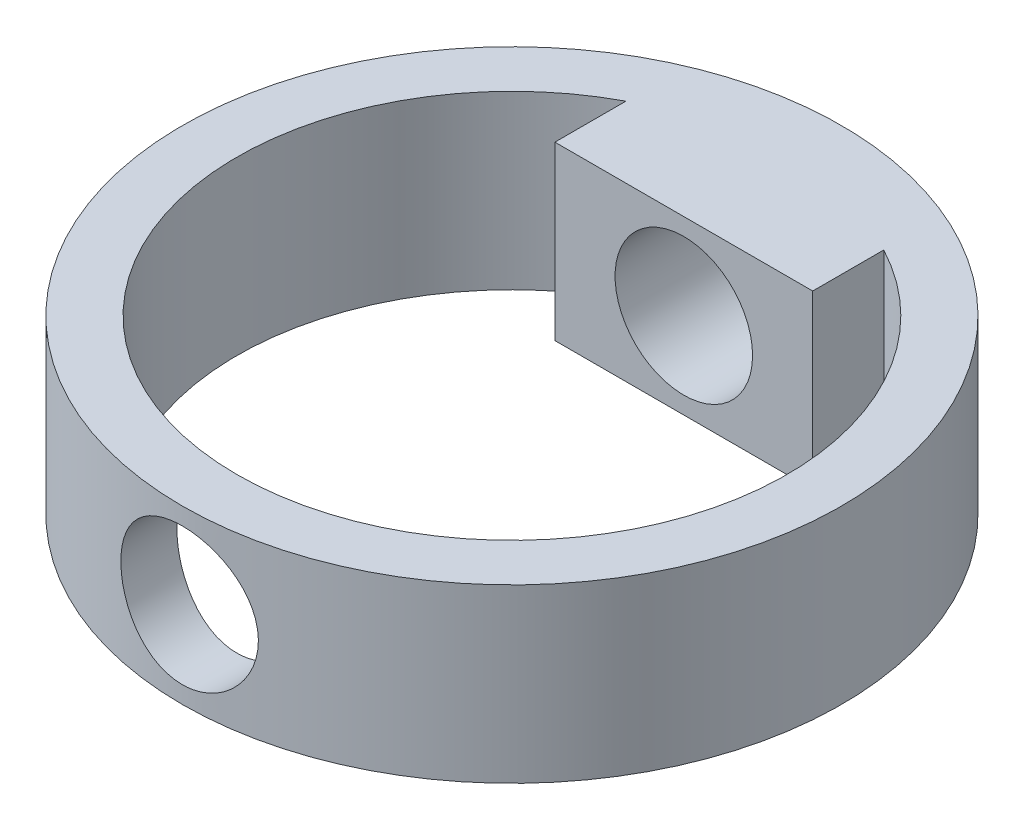
from build123d import *

# Parameters (mm, degrees)
SKETCH6_R               = 19.175
SKETCH6_R_2             = 16
BOSS_EXTRUDE4_DEPTH     = 5
BOSS_EXTRUDE6_REACH     = 37.268
SKETCH8_W               = 15
SKETCH8_H               = 10
CUT_EXTRUDE1_DEPTH      = 31.264603913
CUT_EXTRUDE1_DEPTH_BACK = 31.264603913
SKETCH7_2_R             = 4


with BuildPart() as part:
    # Sketch6 → Boss-Extrude4 (new, symmetric)
    with BuildSketch(Plane(origin=(0, 0, 0), x_dir=(1, 0, 0), z_dir=(0, 1, 0))):
        Circle(SKETCH6_R)
        Circle(SKETCH6_R_2, mode=Mode.SUBTRACT)
    extrude(amount=BOSS_EXTRUDE4_DEPTH, both=True)

    # Sketch8 → Boss-Extrude6 (add, up to next)
    with BuildSketch(Plane.XY.offset(-10), mode=Mode.PRIVATE) as boss_extrude6_sk1:
        Rectangle(SKETCH8_W, SKETCH8_H)
    boss_extrude6_tool1 = extrude(boss_extrude6_sk1.sketch, amount=-BOSS_EXTRUDE6_REACH, mode=Mode.PRIVATE) - part.part
    add(boss_extrude6_tool1.solids().sort_by_distance((0, 0, -10))[0])

    # Sketch7_2 → Cut-Extrude1 (cut, two sides: drawn at the far end of the back side and taken through both)
    with BuildSketch(Plane.XY.offset(3.7).offset(-CUT_EXTRUDE1_DEPTH_BACK)):
        Circle(SKETCH7_2_R)
    extrude(amount=CUT_EXTRUDE1_DEPTH + CUT_EXTRUDE1_DEPTH_BACK, mode=Mode.SUBTRACT)


solid = part.part
